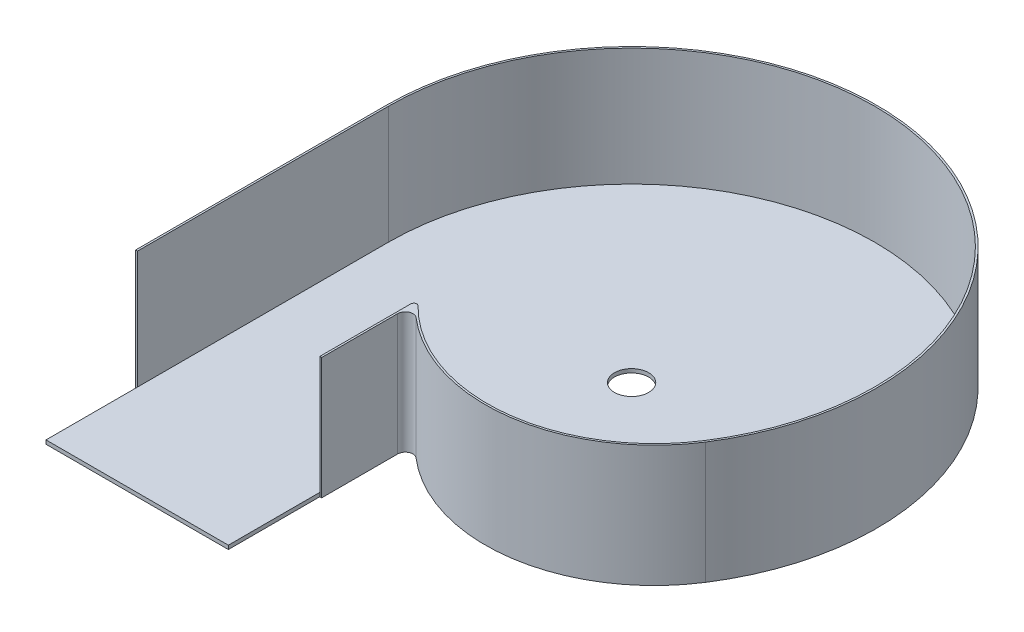
from build123d import *

# Parameters (mm, degrees)
BOSS_EXTRUDE1_DEPTH = 101.6
BOSS_EXTRUDE2_DEPTH = 3.175
SKETCH3_R           = 14.2875
CUT_EXTRUDE1_DEPTH  = 4.175


with BuildPart() as part:
    # Sketch1 → Boss-Extrude1 (new body)
    with BuildSketch(Plane(origin=(0, 0, 0), x_dir=(1, 0, 0), z_dir=(0, 1, 0))):
        with BuildLine():
            Line((-203.2, 0), (-203.2, -209.748302875))
            Line((-203.2, -209.748302875), (-204.7875, -209.748302875))
            Line((-204.7875, -209.748302875), (-204.7875, 0))
            ThreePointArc((-204.7875, 0), (57.689818519, 196.493778516), (172.284391551, -110.706858794))
            ThreePointArc((172.284391551, -110.706858794), (73.781728286, -174.14050958), (-38.721251967, -141.434513854))
            ThreePointArc((-38.721251967, -141.434513854), (-45.510666818, -140.476846169), (-49.2125, -146.248302875))
            Line((-49.2125, -146.248302875), (-49.2125, -209.748302875))
            Line((-49.2125, -209.748302875), (-50.8, -209.748302875))
            Line((-50.8, -209.748302875), (-50.8, -196.747553987))
            Line((-50.8, -196.747553987), (-50.8, -133.791705405))
            ThreePointArc((-50.8, -133.791705405), (-49.219066452, -131.439729313), (-46.444258629, -132.015562597))
            ThreePointArc((-46.444258629, -132.015562597), (67.592808645, -173.307075278), (170.948853632, -109.848666091))
            ThreePointArc((170.948853632, -109.848666091), (57.242610623, 194.970570931), (-203.2, 0))
        make_face()
    extrude(amount=BOSS_EXTRUDE1_DEPTH)

    # Sketch2 → Boss-Extrude2 (add)
    with BuildSketch(Plane(origin=(0, 0, 0), x_dir=(1, 0, 0), z_dir=(0, 1, 0))):
        with BuildLine():
            Line((-50.8, -133.791705405), (-50.8, -286.191705405))
            Line((-50.8, -286.191705405), (-203.2, -286.191705405))
            Line((-203.2, -286.191705405), (-203.2, 0))
            ThreePointArc((-203.2, 0), (57.242610623, 194.970570931), (170.948853632, -109.848666091))
            ThreePointArc((170.948853632, -109.848666091), (67.592808645, -173.307075278), (-46.444258629, -132.015562597))
            ThreePointArc((-46.444258629, -132.015562597), (-49.219066452, -131.439729313), (-50.8, -133.791705405))
        make_face()
    extrude(amount=BOSS_EXTRUDE2_DEPTH)

    # Sketch3 → Cut-Extrude1 (cut, through all)
    with BuildSketch(Plane(origin=(0, 3.175, 0), x_dir=(1, 0, 0), z_dir=(0, 1, 0))):
        Circle(SKETCH3_R)
    extrude(amount=-CUT_EXTRUDE1_DEPTH, mode=Mode.SUBTRACT)


solid = part.part
